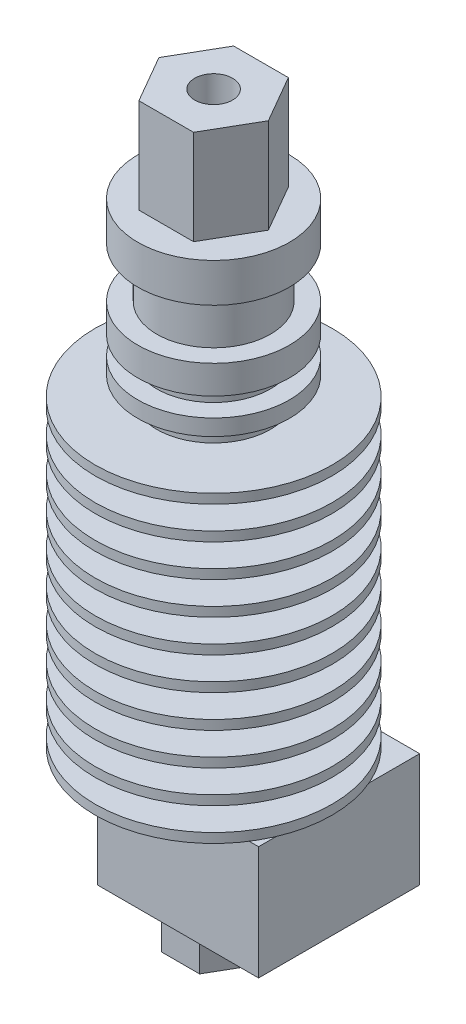
from build123d import *

# Parameters (mm, degrees)
SKETCH2_R           = 1.792662358
SKETCH2_R_2         = 1
BOSS_EXTRUDE1_DEPTH = 3
SKETCH3_W           = 17
SKETCH3_H           = 17
SKETCH3_R           = 1
BOSS_EXTRUDE2_DEPTH = 12
SKETCH4_R           = 1
BOSS_EXTRUDE3_DEPTH = 3
SKETCH8_R           = 2
BOSS_EXTRUDE4_DEPTH = 10


with BuildPart() as part:
    # Sketch1 → Revolve1 (revolve)
    with BuildSketch(Plane.XY):
        Polygon((1, 0), (12.5, 0), (12.5, 1), (8, 1), (8, 3.444444444), (12.5, 3.444444444), (12.5, 4.444444444), (8, 4.444444444), (8, 6.888888889), (12.5, 6.888888889), (12.5, 7.888888889), (8, 7.888888889), (8, 10.333333333), (12.5, 10.333333333), (12.5, 11.333333333), (8, 11.333333333), (8, 13.777777778), (12.5, 13.777777778), (12.5, 14.777777778), (8, 14.777777778), (8, 17.222222222), (12.5, 17.222222222), (12.5, 18.222222222), (8, 18.222222222), (8, 20.666666667), (12.5, 20.666666667), (12.5, 21.666666667), (8, 21.666666667), (8, 24.111111111), (12.5, 24.111111111), (12.5, 25.111111111), (8, 25.111111111), (8, 27.555555556), (12.5, 27.555555556), (12.5, 28.555555556), (8, 28.555555556), (8, 31), (12.5, 31), (12.5, 32), (6, 32), (6, 34), (8, 34), (8, 35.7), (6, 35.7), (6, 37.7), (8, 37.7), (8, 40.7), (6, 40.7), (6, 46), (8, 46), (8, 50.1), (1, 50.1), align=None)
    revolve(axis=Axis((0, 0, 0), (0, 1, 0)))

    # Sketch2 → Boss-Extrude1 (add)
    with BuildSketch(Plane.XZ):
        Circle(SKETCH2_R)
        Circle(SKETCH2_R_2, mode=Mode.SUBTRACT)
    extrude(amount=BOSS_EXTRUDE1_DEPTH)

    # Sketch8 → Boss-Extrude4 (add)
    with BuildSketch(Plane(origin=(0, 50.1, 0), x_dir=(1, 0, 0), z_dir=(0, 1, 0))):
        Polygon((2.886751346, 5), (-2.886751346, 5), (-5.773502692, 0), (-2.886751346, -5), (2.886751346, -5), (5.773502692, 0), align=None)
        Circle(SKETCH8_R, mode=Mode.SUBTRACT)
    extrude(amount=BOSS_EXTRUDE4_DEPTH)


with BuildPart() as body_2:
    # Sketch3 → Boss-Extrude2 (new body)
    with BuildSketch(Plane.XZ.offset(3)):
        with Locations((0, -4.742198182)):
            Rectangle(SKETCH3_W, SKETCH3_H)
        Circle(SKETCH3_R, mode=Mode.SUBTRACT)
    extrude(amount=BOSS_EXTRUDE2_DEPTH)

    # Sketch4 → Boss-Extrude3 (add)
    with BuildSketch(Plane.XZ.offset(15)):
        Polygon((2.020725942, 3.5), (-2.020725942, 3.5), (-4.041451884, 0), (-2.020725942, -3.5), (2.020725942, -3.5), (4.041451884, 0), align=None)
        Circle(SKETCH4_R, mode=Mode.SUBTRACT)
    extrude(amount=BOSS_EXTRUDE3_DEPTH)

    # Sketch5 → Revolve2 (revolve)
    with BuildSketch(Plane.XY):
        Polygon((0.2, -18), (0.2, -20), (2.945271199, -18), align=None)
    revolve(axis=Axis((0, 0, 0), (0, -1, 0)))


solid = Compound([part.part, body_2.part])
